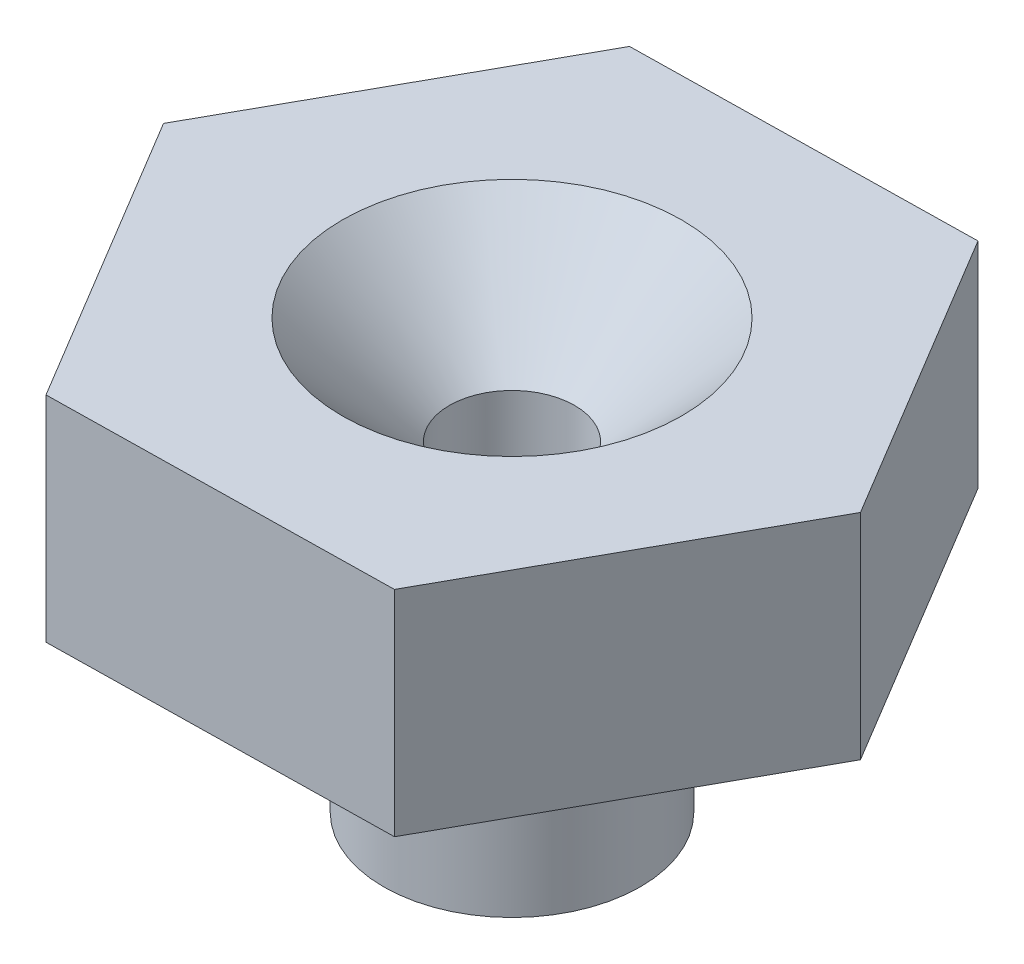
from build123d import *

# Parameters (mm, degrees)
BOSS_EXTRUDE1_DEPTH = 10
SKETCH2_R           = 6
BOSS_EXTRUDE2_DEPTH = 10
SKETCH3_R           = 2.925
CUT_EXTRUDE1_DEPTH  = 21
FILLET1_R           = 4
CHAMFER1_SIZE       = 5


with BuildPart() as part:
    # Sketch1 → Boss-Extrude1 (new body)
    with BuildSketch(Plane(origin=(0, 0, 0), x_dir=(1, 0, 0), z_dir=(0, 1, 0))):
        Polygon((7.764943234, 13.989483785), (-8.232776727, 13.719379992), (-15.997719961, -0.270103793), (-7.764943234, -13.989483785), (8.232776727, -13.719379992), (15.997719961, 0.270103793), align=None)
    extrude(amount=BOSS_EXTRUDE1_DEPTH)

    # Sketch2 → Boss-Extrude2 (add)
    with BuildSketch(Plane.XZ):
        Circle(SKETCH2_R)
    extrude(amount=BOSS_EXTRUDE2_DEPTH)

    # Sketch3 → Cut-Extrude1 (cut, through all)
    with BuildSketch(Plane.XZ.offset(10)):
        Circle(SKETCH3_R)
    extrude(amount=-CUT_EXTRUDE1_DEPTH, mode=Mode.SUBTRACT)

    # Fillet1
    fillet1_edges = [part.edges().sort_by_distance(p)[0] for p in [
        (-6, 0, 0),
    ]]
    fillet(fillet1_edges, radius=FILLET1_R)

    # Chamfer1
    chamfer1_edges = [part.edges().sort_by_distance(p)[0] for p in [
        (-2.925, 10, 0),
    ]]
    chamfer(chamfer1_edges, length=CHAMFER1_SIZE)


solid = part.part
